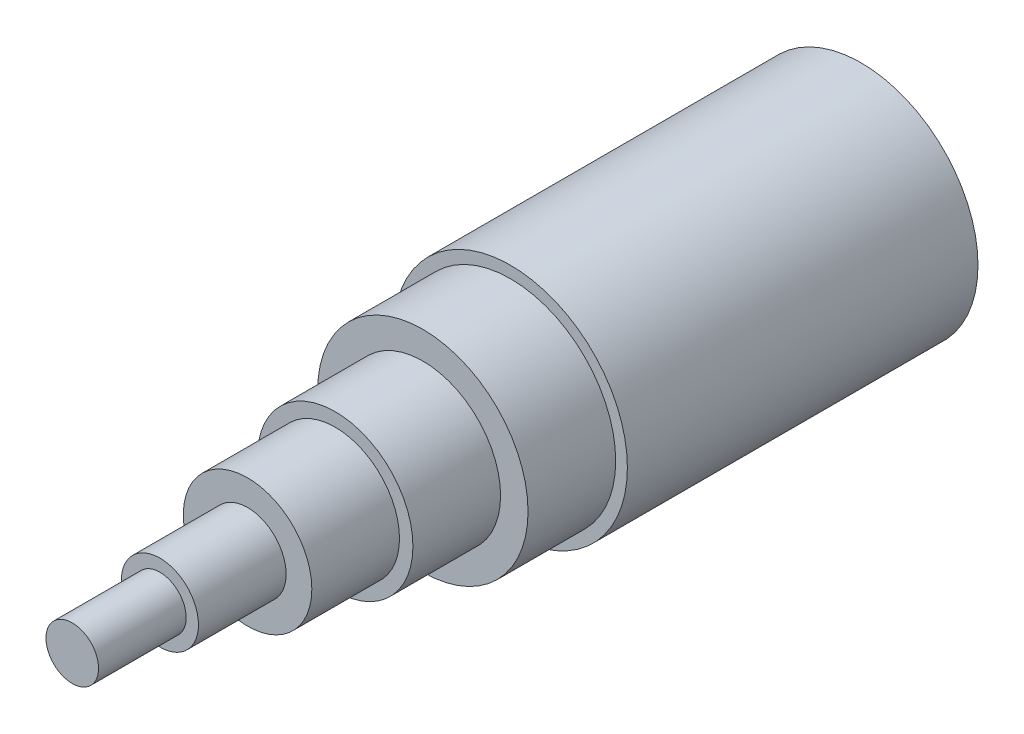
from build123d import *

# Parameters (mm, degrees)
SKETCH1_R           = 1
BOSS_EXTRUDE1_DEPTH = 3
SKETCH2_R           = 0.33
SKETCH2_R_2         = 0.225
BOSS_EXTRUDE2_DEPTH = 3
SKETCH2_3_R         = 0.55
SKETCH2_3_R_2       = 0.33
BOSS_EXTRUDE3_DEPTH = 2.25
SKETCH2_4_R         = 0.665
SKETCH2_4_R_2       = 0.55
BOSS_EXTRUDE4_DEPTH = 1.5
SKETCH2_6_R         = 0.9
SKETCH2_6_R_2       = 0.665
BOSS_EXTRUDE6_DEPTH = 0.75
SKETCH2_7_R         = 0.225
BOSS_EXTRUDE7_DEPTH = 3.75


with BuildPart() as part:
    # Sketch1 → Boss-Extrude1 (new body)
    with BuildSketch(Plane.XY):
        Circle(SKETCH1_R)
    extrude(amount=BOSS_EXTRUDE1_DEPTH)

    # Sketch2 → Boss-Extrude2 (add)
    with BuildSketch(Plane.XY.offset(3)):
        Circle(SKETCH2_R)
        Circle(SKETCH2_R_2, mode=Mode.SUBTRACT)
    extrude(amount=BOSS_EXTRUDE2_DEPTH)

    # Sketch2_3 → Boss-Extrude3 (add)
    with BuildSketch(Plane.XY.offset(3)):
        Circle(SKETCH2_3_R)
        Circle(SKETCH2_3_R_2, mode=Mode.SUBTRACT)
    extrude(amount=BOSS_EXTRUDE3_DEPTH)

    # Sketch2_4 → Boss-Extrude4 (add)
    with BuildSketch(Plane.XY.offset(3)):
        Circle(SKETCH2_4_R)
        Circle(SKETCH2_4_R_2, mode=Mode.SUBTRACT)
    extrude(amount=BOSS_EXTRUDE4_DEPTH)

    # Sketch2_6 → Boss-Extrude6 (add)
    with BuildSketch(Plane.XY.offset(3)):
        Circle(SKETCH2_6_R)
        Circle(SKETCH2_6_R_2, mode=Mode.SUBTRACT)
    extrude(amount=BOSS_EXTRUDE6_DEPTH)

    # Sketch2_7 → Boss-Extrude7 (add)
    with BuildSketch(Plane.XY.offset(3)):
        Circle(SKETCH2_7_R)
    extrude(amount=BOSS_EXTRUDE7_DEPTH)


solid = part.part
